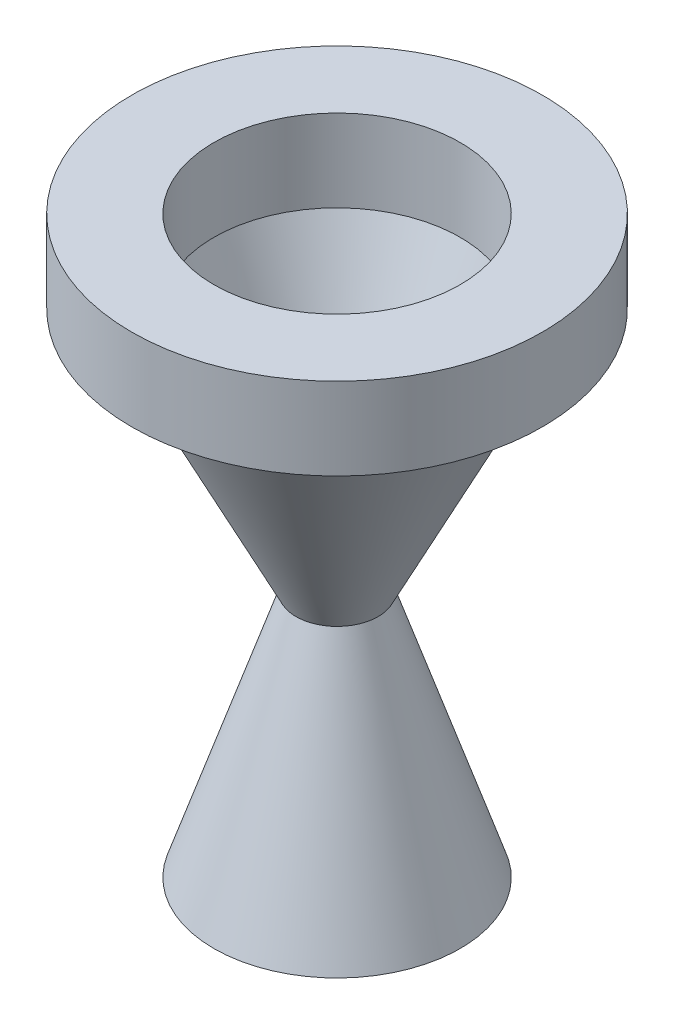
from build123d import *

# Parameters (mm, degrees)
SKETCH1_R           = 63.5
SKETCH1_R_2         = 38.1
BOSS_EXTRUDE1_DEPTH = 25.4
FILLET1_R           = 5.08


with BuildPart() as part:
    # Sketch1 → Boss-Extrude1 (new body)
    with BuildSketch(Plane(origin=(0, 0, 0), x_dir=(1, 0, 0), z_dir=(0, 1, 0))):
        Circle(SKETCH1_R)
        Circle(SKETCH1_R_2, mode=Mode.SUBTRACT)
    extrude(amount=BOSS_EXTRUDE1_DEPTH)

    # Sketch4 → Revolve1 (revolve)
    with BuildSketch(Plane.XY):
        Polygon((50.8, 0), (12.7, -76.2), (6.35, -76.2), (38.1, 0), align=None)
    revolve(axis=Axis((0, -76.2, 0), (0, 1, 0)))

    # Sketch6 → Revolve2 (revolve)
    with BuildSketch(Plane.XY):
        Polygon((12.7, -76.2), (38.1, -152.4), (25.4, -152.4), (6.35, -76.2), align=None)
    revolve(axis=Axis((0, -76.2, 0), (0, -1, 0)))

    # Fillet1
    fillet1_edges = [part.edges().sort_by_distance(p)[0] for p in [
        (-6.35, -76.2, 0),
    ]]
    fillet(fillet1_edges, radius=FILLET1_R)


solid = part.part
